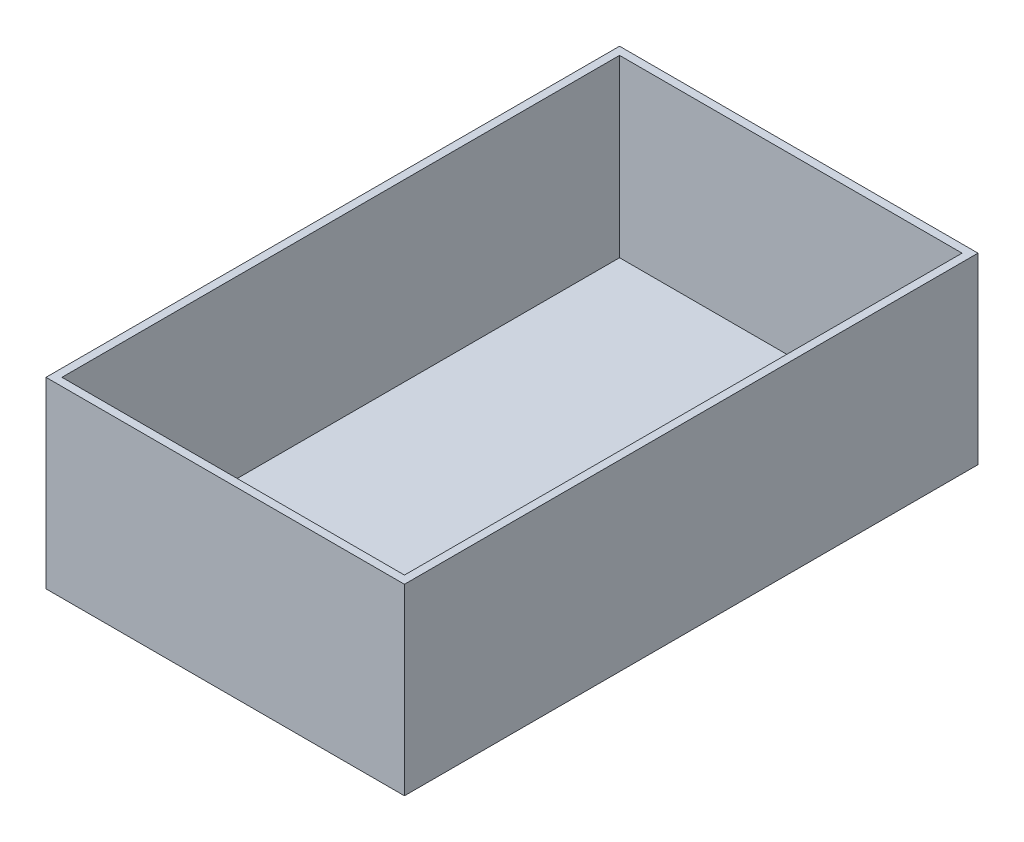
from build123d import *

# Parameters (mm, degrees)
SKETCH1_W           = 136.525
SKETCH1_H           = 222.25
BOSS_EXTRUDE1_DEPTH = 69.85
SHELL1_T            = 3.175


with BuildPart() as part:
    # Sketch1 → Boss-Extrude1 (new body)
    with BuildSketch(Plane(origin=(0, 0, 0), x_dir=(1, 0, 0), z_dir=(0, 1, 0))):
        with Locations((14.713825088, -36.711638693)):
            Rectangle(SKETCH1_W, SKETCH1_H)
    extrude(amount=BOSS_EXTRUDE1_DEPTH)

    # Shell1
    shell1_openings = [part.faces().sort_by_distance(p)[0] for p in [
        (14.713825088, 69.85, 36.711638693),
    ]]
    offset(amount=SHELL1_T, openings=shell1_openings, kind=Kind.INTERSECTION)


solid = part.part
